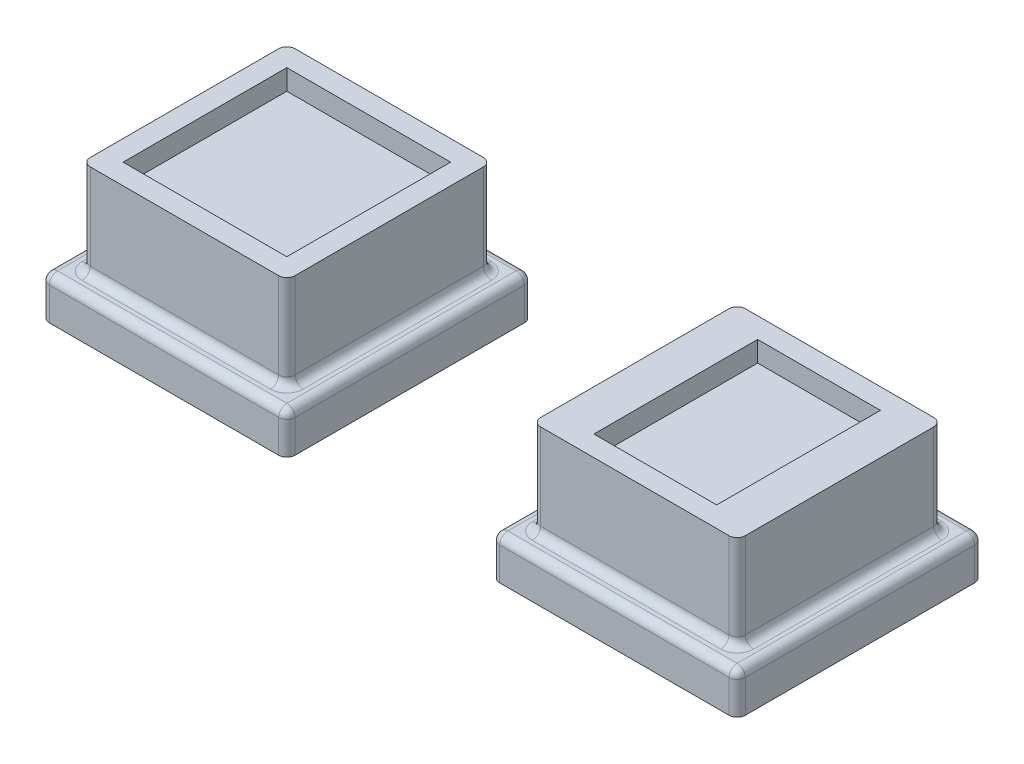
from build123d import *

# Parameters (mm, degrees)
SKETCH_1_W          = 60
SKETCH_1_H          = 60
EXTRUDE_1_DEPTH     = 10
EXTRUDE_1_2_DEPTH   = 10
SKETCH_4_W          = 50
SKETCH_4_H          = 50
EXTRUDE_3_DEPTH     = 23
FILLET_6_R          = 2
FILLET_7_R          = 2
SKETCH_5_W          = 40
SKETCH_5_H          = 40
CUT_EXTRUDE_1_DEPTH = 5
SKETCH_6_W          = 30
SKETCH_6_H          = 40
CUT_EXTRUDE_2_DEPTH = 5
FILLET_8_R          = 2


with BuildPart() as part:
    # 스케치1 → 보스-돌출1 (new body)
    with BuildSketch(Plane(origin=(0, 0, 0), x_dir=(1, 0, 0), z_dir=(0, 1, 0))):
        with Locations((-55, 0)):
            Rectangle(SKETCH_1_W, SKETCH_1_H)
    extrude(amount=EXTRUDE_1_DEPTH)



with BuildPart() as body_2:
    # 스케치1 → Extrude 1 2 (new body)
    with BuildSketch(Plane(origin=(0, 0, 0), x_dir=(1, 0, 0), z_dir=(0, 1, 0))):
        with Locations((55, 0)):
            Rectangle(SKETCH_1_W, SKETCH_1_H)
    extrude(amount=EXTRUDE_1_2_DEPTH)


with BuildPart() as part_1:
    add(part.part)

    add(body_2.part)  # 보스-돌출3 merges body 2
    # 스케치4 → 보스-돌출3 (add)
    with BuildSketch(Plane(origin=(0, 10, 0), x_dir=(1, 0, 0), z_dir=(0, 1, 0))):
        with Locations((-55, 0)):
            Rectangle(SKETCH_4_W, SKETCH_4_H)
        with Locations((55, 0)):
            Rectangle(SKETCH_4_W, SKETCH_4_H)
    extrude(amount=EXTRUDE_3_DEPTH)

    # 필렛6
    fillet_6_edges = [part_1.edges().sort_by_distance(p)[0] for p in [
        (-25, 10, 0),
        (-55, 10, -30),
        (-80, 10, 0),
        (-80, 21.5, -25),
        (-55, 10, 25),
        (-80, 21.5, 25),
        (-30, 10, 0),
        (-30, 21.5, 25),
        (-55, 10, -25),
        (-30, 21.5, -25),
        (-85, 10, 0),
        (-85, 5, -30),
        (-25, 5, -30),
        (-25, 5, 30),
        (-85, 5, 30),
        (-55, 10, 30),
    ]]
    fillet(fillet_6_edges, radius=FILLET_6_R)

    # 필렛7
    fillet_7_edges = [part_1.edges().sort_by_distance(p)[0] for p in [
        (30, 21.5, -25),
        (30, 21.5, 25),
        (80, 21.5, 25),
        (80, 21.5, -25),
        (25, 10, 0),
        (55, 10, 30),
        (85, 10, 0),
        (55, 10, -30),
        (25, 5, -30),
        (85, 5, -30),
        (85, 5, 30),
        (25, 5, 30),
    ]]
    fillet(fillet_7_edges, radius=FILLET_7_R)

    # 스케치5 → 컷-돌출1 (cut)
    with BuildSketch(Plane(origin=(0, 33, 0), x_dir=(1, 0, 0), z_dir=(0, 1, 0))):
        with Locations((-55, 0)):
            Rectangle(SKETCH_5_W, SKETCH_5_H)
    extrude(amount=-CUT_EXTRUDE_1_DEPTH, mode=Mode.SUBTRACT)

    # 스케치6 → 컷-돌출2 (cut)
    with BuildSketch(Plane(origin=(0, 33, 0), x_dir=(1, 0, 0), z_dir=(0, 1, 0))):
        with Locations((55, 0)):
            Rectangle(SKETCH_6_W, SKETCH_6_H)
    extrude(amount=-CUT_EXTRUDE_2_DEPTH, mode=Mode.SUBTRACT)

    # 필렛8
    fillet_8_edges = [part_1.edges().sort_by_distance(p)[0] for p in [
        (30, 10, 0),
        (55, 10, -25),
        (80, 10, 0),
        (55, 10, 25),
        (30.585786438, 10, 24.414213562),
        (30.585786438, 10, -24.414213562),
        (79.414213562, 10, -24.414213562),
        (79.414213562, 10, 24.414213562),
    ]]
    fillet(fillet_8_edges, radius=FILLET_8_R)


solid = part_1.part
